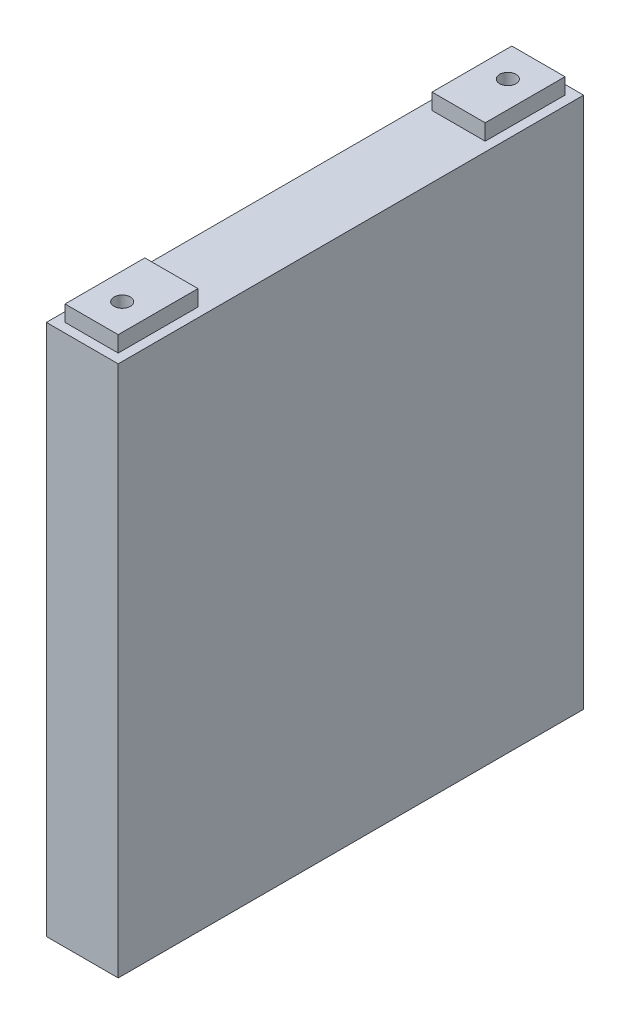
from build123d import *

# Parameters (mm, degrees)
SKETCH1_W           = 27
SKETCH1_H           = 175
BOSS_EXTRUDE1_DEPTH = 200
SKETCH2_W           = 20
SKETCH2_H           = 30
SKETCH2_R           = 3.071880825
BOSS_EXTRUDE2_DEPTH = 6


with BuildPart() as part:
    # Sketch1 → Boss-Extrude1 (new body)
    with BuildSketch(Plane(origin=(0, 0, 0), x_dir=(1, 0, 0), z_dir=(0, 1, 0))):
        Rectangle(SKETCH1_W, SKETCH1_H)
    extrude(amount=BOSS_EXTRUDE1_DEPTH)

    # Sketch2 → Boss-Extrude2 (add)
    with BuildSketch(Plane(origin=(0, 200, 0), x_dir=(1, 0, 0), z_dir=(0, 1, 0))):
        with Locations((0, -69)):
            Rectangle(SKETCH2_W, SKETCH2_H)
        with Locations((0, -72.5)):
            Circle(SKETCH2_R, mode=Mode.SUBTRACT)
        with Locations((0, 69)):
            Rectangle(SKETCH2_W, SKETCH2_H)
        with Locations((0, 72.5)):
            Circle(SKETCH2_R, mode=Mode.SUBTRACT)
    extrude(amount=BOSS_EXTRUDE2_DEPTH)


solid = part.part
